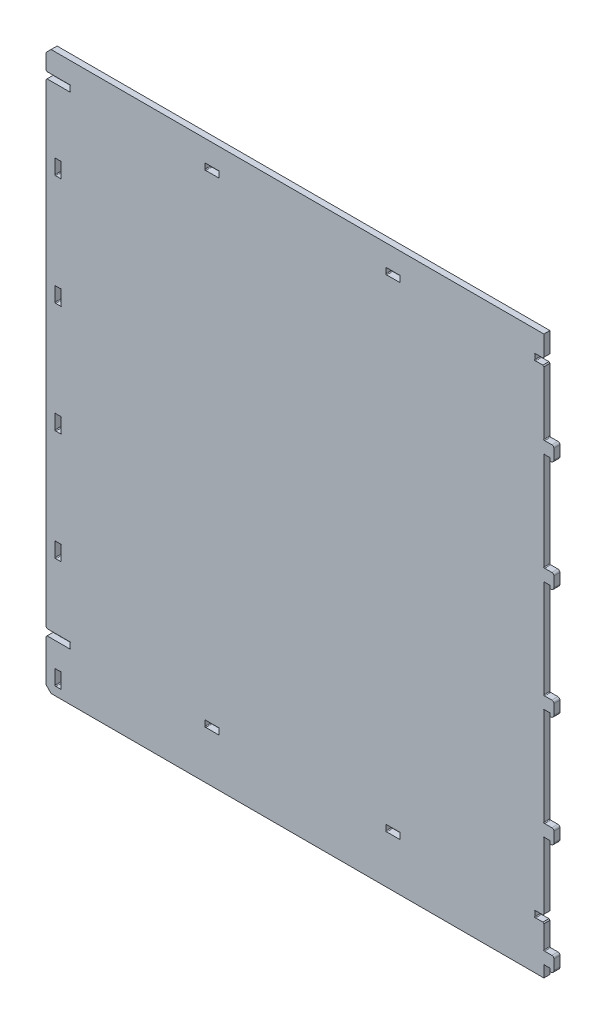
from build123d import *

# Parameters (mm, degrees)
SKETCH1_W                  = 495.4
SKETCH1_H                  = 555
BOSS_EXTRUDE1_DEPTH        = 6
BOSS_EXTRUDE2_DEPTH        = 6
SKETCH2_W                  = 6
SKETCH2_H                  = 15
CUT_EXTRUDE1_DEPTH         = 7
SKETCH6_R                  = 0.5
CUT_EXTRUDE4_DEPTH         = 7
LPATTERN1_COUNT            = 5
LPATTERN1_PITCH            = 110
SKETCH5_W                  = 24
SKETCH5_H                  = 6.2
SKETCH5_W_2                = 9
CUT_EXTRUDE3_DEPTH         = 6
SKETCH7_R                  = 0.5
CUT_EXTRUDE5_DEPTH         = 7
SKETCH8_W                  = 14
SKETCH8_H                  = 6.2
CUT_EXTRUDE6_DEPTH         = 7
SKETCH9_R                  = 0.5
CUT_EXTRUDE7_DEPTH         = 7
LPATTERN4_COUNT            = 2
LPATTERN4_PITCH            = 180
CHAMFER2_SIZE              = 1
LPATTERN3_COUNT            = 2
LPATTERN3_PITCH            = 480
LPATTERN3_COPY_1_SKETCH_W  = 14
LPATTERN3_COPY_1_SKETCH_H  = 6.2
LPATTERN3_COPY_1_DEPTH     = 7
LPATTERN3_COPY_2_SKETCH_R  = 0.5
LPATTERN3_COPY_2_DEPTH     = 7
CHAMFER2_OF_LPATTERN3_SIZE = 1
CHAMFER1_SIZE              = 5


with BuildPart() as part:
    # Sketch1 → Boss-Extrude1 (new body)
    with BuildSketch(Plane.XY):
        with Locations((247.7, 277.5)):
            Rectangle(SKETCH1_W, SKETCH1_H)
    extrude(amount=BOSS_EXTRUDE1_DEPTH)

    # Sketch3 → Boss-Extrude2 (add)
    with BuildSketch(Plane.XY.offset(6)):
        with BuildLine():
            Line((495.4, 23.5), (503.4, 23.5))
            ThreePointArc((503.4, 23.5), (504.814213562, 22.914213562), (505.4, 21.5))
            Line((505.4, 21.5), (505.4, 11.5))
            ThreePointArc((505.4, 11.5), (504.521320344, 9.378679656), (502.4, 8.5))
            ThreePointArc((502.4, 8.5), (501.692893219, 8.792893219), (501.4, 9.5))
            Line((501.4, 9.5), (501.4, 11.5))
            Line((501.4, 11.5), (495.4, 11.5))
            Line((495.4, 11.5), (495.4, 23.5))
        make_face()
    boss_extrude2 = extrude(amount=-BOSS_EXTRUDE2_DEPTH)

    # Sketch2 → Cut-Extrude1 (cut, through all)
    with BuildSketch(Plane.XY.offset(6)):
        with Locations((12, 16)):
            Rectangle(SKETCH2_W, SKETCH2_H)
    cut_extrude1 = extrude(amount=-CUT_EXTRUDE1_DEPTH, mode=Mode.SUBTRACT)

    # Sketch6 → Cut-Extrude4 (cut, through all)
    with BuildSketch(Plane.XY.offset(6)):
        with Locations((9.353553391, 8.853553391)):
            Circle(SKETCH6_R)
        with Locations((14.646446609, 8.853553391)):
            Circle(SKETCH6_R)
        with Locations((14.646446609, 23.146446609)):
            Circle(SKETCH6_R)
        with Locations((9.353553391, 23.146446609)):
            Circle(SKETCH6_R)
        with Locations((495.753553391, 23.853553391)):
            Circle(SKETCH6_R)
        with Locations((501.046446609, 11.146446609)):
            Circle(SKETCH6_R)
        with Locations((495.753553391, 11.146446609)):
            Circle(SKETCH6_R)
    cut_extrude4 = extrude(amount=-CUT_EXTRUDE4_DEPTH, mode=Mode.SUBTRACT)

    # LPattern1: Boss-Extrude2, Cut-Extrude1, Cut-Extrude4 ×5
    with Locations(*[(0, i * LPATTERN1_PITCH, 0) for i in range(1, LPATTERN1_COUNT)]):
        add(boss_extrude2)
        add(cut_extrude1, mode=Mode.SUBTRACT)
        add(cut_extrude4, mode=Mode.SUBTRACT)

    # Sketch5 → Cut-Extrude3 (cut)
    with BuildSketch(Plane.XY.offset(6)):
        with Locations((12, 50.8)):
            Rectangle(SKETCH5_W, SKETCH5_H)
        with Locations((490.9, 50.8)):
            Rectangle(SKETCH5_W_2, SKETCH5_H)
    cut_extrude3 = extrude(amount=-CUT_EXTRUDE3_DEPTH, mode=Mode.SUBTRACT)

    # Sketch7 → Cut-Extrude5 (cut, through all)
    with BuildSketch(Plane.XY.offset(6)):
        with Locations((486.753553391, 53.546446609)):
            Circle(SKETCH7_R)
        with Locations((486.753553391, 48.053553391)):
            Circle(SKETCH7_R)
        with Locations((23.646446609, 53.546446609)):
            Circle(SKETCH7_R)
        with Locations((23.646446609, 48.053553391)):
            Circle(SKETCH7_R)
    cut_extrude5 = extrude(amount=-CUT_EXTRUDE5_DEPTH, mode=Mode.SUBTRACT)

    # Sketch8 → Cut-Extrude6 (cut, through all)
    with BuildSketch(Plane.XY.offset(6)):
        with Locations((165.2, 50.8)):
            Rectangle(SKETCH8_W, SKETCH8_H)
    cut_extrude6 = extrude(amount=-CUT_EXTRUDE6_DEPTH, mode=Mode.SUBTRACT)

    # Sketch9 → Cut-Extrude7 (cut, through all)
    with BuildSketch(Plane.XY.offset(6)):
        with Locations((158.553553391, 53.546446609)):
            Circle(SKETCH9_R)
        with Locations((158.553553391, 48.053553391)):
            Circle(SKETCH9_R)
        with Locations((171.846446609, 48.053553391)):
            Circle(SKETCH9_R)
        with Locations((171.846446609, 53.546446609)):
            Circle(SKETCH9_R)
    cut_extrude7 = extrude(amount=-CUT_EXTRUDE7_DEPTH, mode=Mode.SUBTRACT)

    # LPattern4: Cut-Extrude6, Cut-Extrude7 ×2
    with Locations(*[(i * LPATTERN4_PITCH, 0, 0) for i in range(1, LPATTERN4_COUNT)]):
        add(cut_extrude6, mode=Mode.SUBTRACT)
        add(cut_extrude7, mode=Mode.SUBTRACT)

    # Chamfer2
    chamfer2_edges = [part.edges().sort_by_distance(p)[0] for p in [
        (0, 53.9, 3),
        (0, 47.7, 3),
        (495.4, 53.9, 3),
        (495.4, 47.7, 3),
    ]]
    chamfer(chamfer2_edges, length=CHAMFER2_SIZE)

    # LPattern3: Cut-Extrude3, Cut-Extrude5, Cut-Extrude6, Cut-Extrude7 ×2
    with Locations(*[(0, i * LPATTERN3_PITCH, 0) for i in range(1, LPATTERN3_COUNT)]):
        add(cut_extrude3, mode=Mode.SUBTRACT)
        add(cut_extrude5, mode=Mode.SUBTRACT)
        add(cut_extrude6, mode=Mode.SUBTRACT)
        add(cut_extrude7, mode=Mode.SUBTRACT)

    # LPattern3 copy 1 sketch → LPattern3 copy 1 (cut, through all)
    with BuildSketch(Plane(origin=(180, 480, 6), x_dir=(1, 0, 0), z_dir=(0, 0, 1))):
        with Locations((165.2, 50.8)):
            Rectangle(LPATTERN3_COPY_1_SKETCH_W, LPATTERN3_COPY_1_SKETCH_H)
    extrude(amount=-LPATTERN3_COPY_1_DEPTH, mode=Mode.SUBTRACT)

    # LPattern3 copy 2 sketch → LPattern3 copy 2 (cut, through all)
    with BuildSketch(Plane(origin=(180, 480, 6), x_dir=(1, 0, 0), z_dir=(0, 0, 1))):
        with Locations((158.553553391, 53.546446609)):
            Circle(LPATTERN3_COPY_2_SKETCH_R)
        with Locations((158.553553391, 48.053553391)):
            Circle(LPATTERN3_COPY_2_SKETCH_R)
        with Locations((171.846446609, 48.053553391)):
            Circle(LPATTERN3_COPY_2_SKETCH_R)
        with Locations((171.846446609, 53.546446609)):
            Circle(LPATTERN3_COPY_2_SKETCH_R)
    extrude(amount=-LPATTERN3_COPY_2_DEPTH, mode=Mode.SUBTRACT)

    # Chamfer2 of LPattern3
    chamfer2_of_lpattern3_edges = [part.edges().sort_by_distance(p)[0] for p in [
        (0, 533.9, 3),
        (0, 527.7, 3),
        (495.4, 533.9, 3),
        (495.4, 527.7, 3),
    ]]
    chamfer(chamfer2_of_lpattern3_edges, length=CHAMFER2_OF_LPATTERN3_SIZE)

    # Chamfer1
    chamfer1_edges = [part.edges().sort_by_distance(p)[0] for p in [
        (0, 555, 3),
        (0, 0, 3),
    ]]
    chamfer(chamfer1_edges, length=CHAMFER1_SIZE)


solid = part.part
